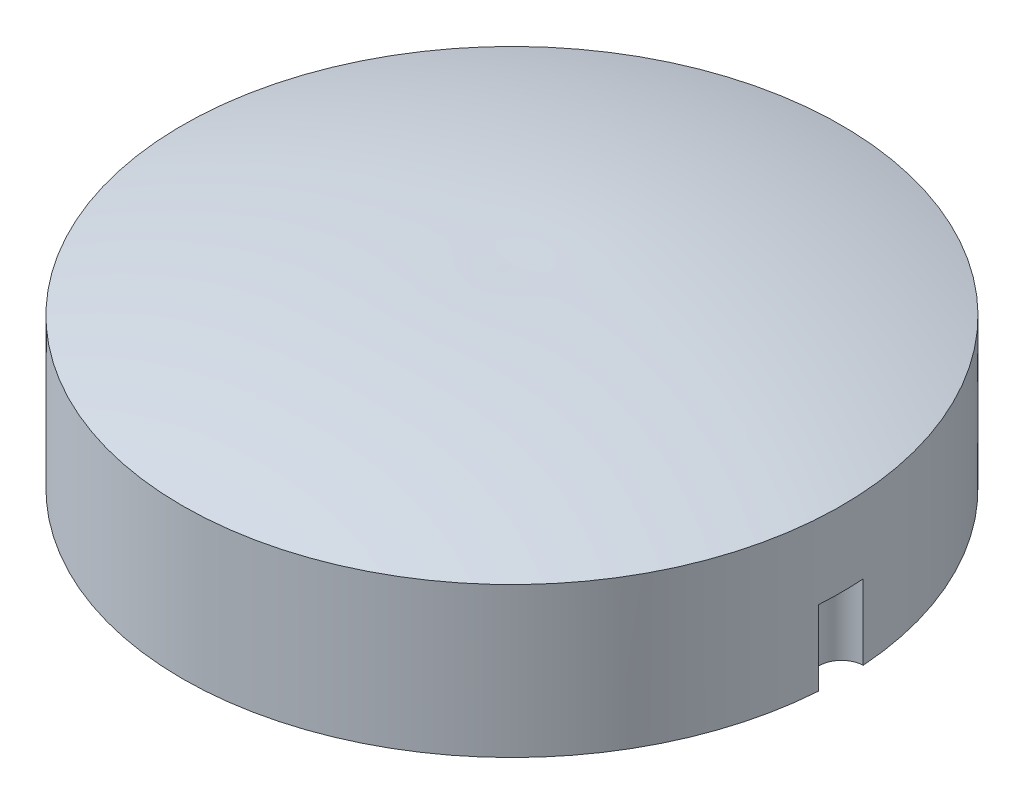
from build123d import *

# Parameters (mm, degrees)
SKETCH3_R          = 1.5
CUT_EXTRUDE1_DEPTH = 5


with BuildPart() as part:
    # Sketch1 → Revolve2 (revolve)
    with BuildSketch(Plane.XY, mode=Mode.PRIVATE) as revolve2_sk:
        with BuildLine():
            Line((0, 0), (22, 0))
            Line((22, 0), (22, 10))
            ThreePointArc((22, 10), (11.13022633, 12.454993089), (0, 13))
            Line((0, 13), (0, 0))
        make_face()
    revolve(revolve2_sk.sketch.rotate(Axis((0, 28.304964539, 0), (0, -1, 0)), 90), axis=Axis((0, 28.304964539, 0), (0, -1, 0)))  # turned: the seam where the file's is

    # Sketch3 → Cut-Extrude1 (cut)
    with BuildSketch(Plane.XZ):
        with Locations((22, 0)):
            Circle(SKETCH3_R)
    extrude(amount=-CUT_EXTRUDE1_DEPTH, mode=Mode.SUBTRACT)


solid = part.part
